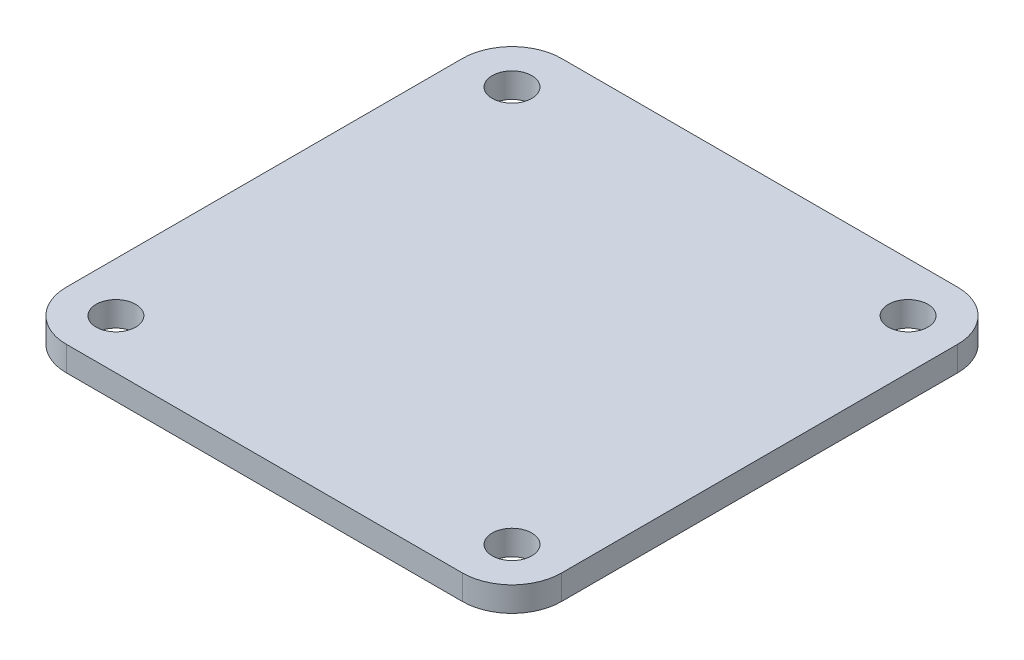
from build123d import *

# Parameters (mm, degrees)
SKETCH1_W                 = 100
SKETCH1_H                 = 100
BOSS_EXTRUDE1_DEPTH       = 5
F_8_0MM_DOWEL_HOLE1_D     = 8
F_8_0MM_DOWEL_HOLE1_DEPTH = 5
FILLET1_R                 = 10


with BuildPart() as part:
    # Sketch1 → Boss-Extrude1 (new body)
    with BuildSketch(Plane(origin=(0, 0, 0), x_dir=(1, 0, 0), z_dir=(0, 1, 0))):
        Rectangle(SKETCH1_W, SKETCH1_H)
    extrude(amount=BOSS_EXTRUDE1_DEPTH)

    # Ø8.0mm Dowel Hole1
    with Locations(Plane(origin=(0, 5, 0), x_dir=(1, 0, 0), z_dir=(0, 1, 0))):
        with Locations((-40, -40), (-40, 40), (40, 40), (40, -40)):
            Hole(F_8_0MM_DOWEL_HOLE1_D / 2, depth=F_8_0MM_DOWEL_HOLE1_DEPTH)

    # Fillet1
    fillet1_edges = [part.edges().sort_by_distance(p)[0] for p in [
        (-50, 2.5, -50),
        (50, 2.5, -50),
        (50, 2.5, 50),
        (-50, 2.5, 50),
    ]]
    fillet(fillet1_edges, radius=FILLET1_R)


solid = part.part
